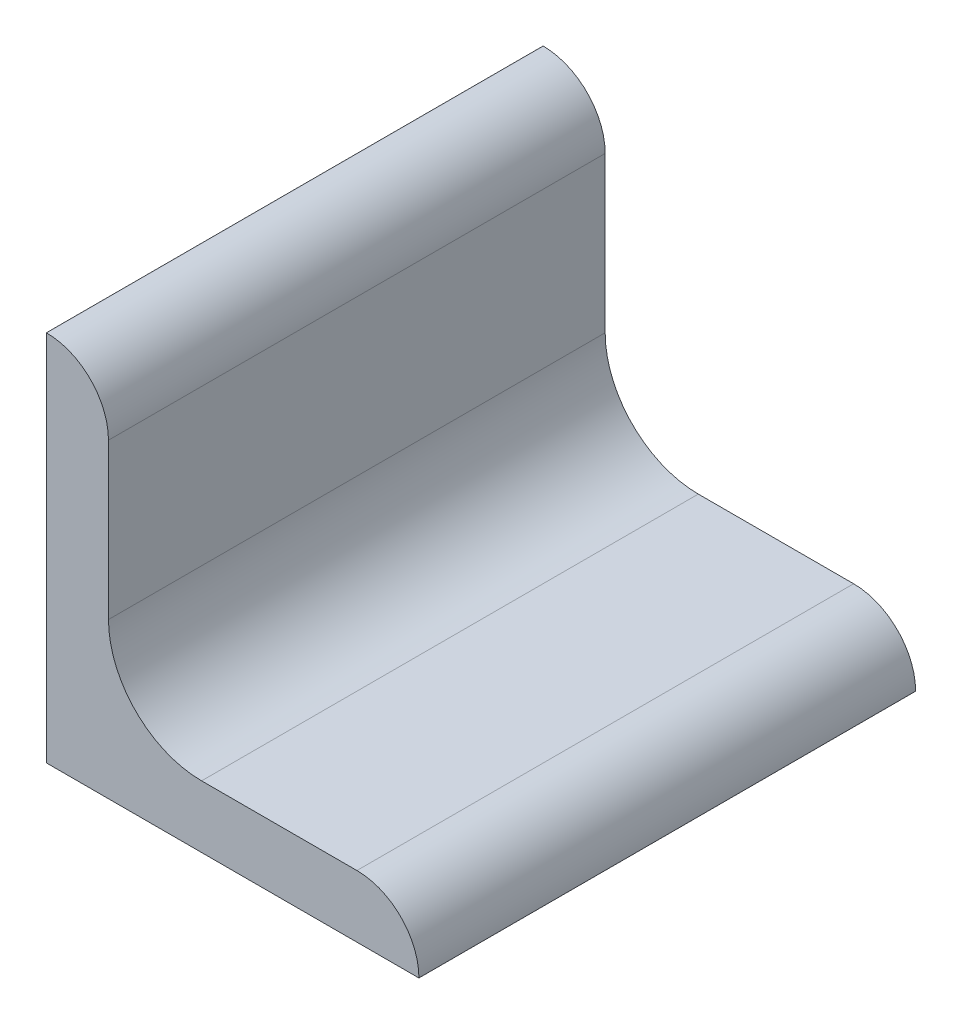
from build123d import *

# Parameters (mm, degrees)
BASESTEELANGLE_DEPTH = 12.7


with BuildPart() as part:
    # Sketch1 → BaseSteelAngle (new body, symmetric)
    with BuildSketch(Plane.XY):
        with BuildLine():
            Line((0, 0), (0, 19.05))
            Line((0, 19.05), (0.00508, 19.05))
            ThreePointArc((0.00508, 19.05), (2.246551928, 18.121551928), (3.175, 15.88008))
            Line((3.175, 15.88008), (3.175, 7.9375))
            ThreePointArc((3.175, 7.9375), (4.569903955, 4.569903955), (7.9375, 3.175))
            Line((7.9375, 3.175), (15.88008, 3.175))
            ThreePointArc((15.88008, 3.175), (18.121551928, 2.246551928), (19.05, 0.00508))
            Line((19.05, 0.00508), (19.05, 0))
            Line((19.05, 0), (0, 0))
        make_face()
    extrude(amount=BASESTEELANGLE_DEPTH, both=True)


solid = part.part
